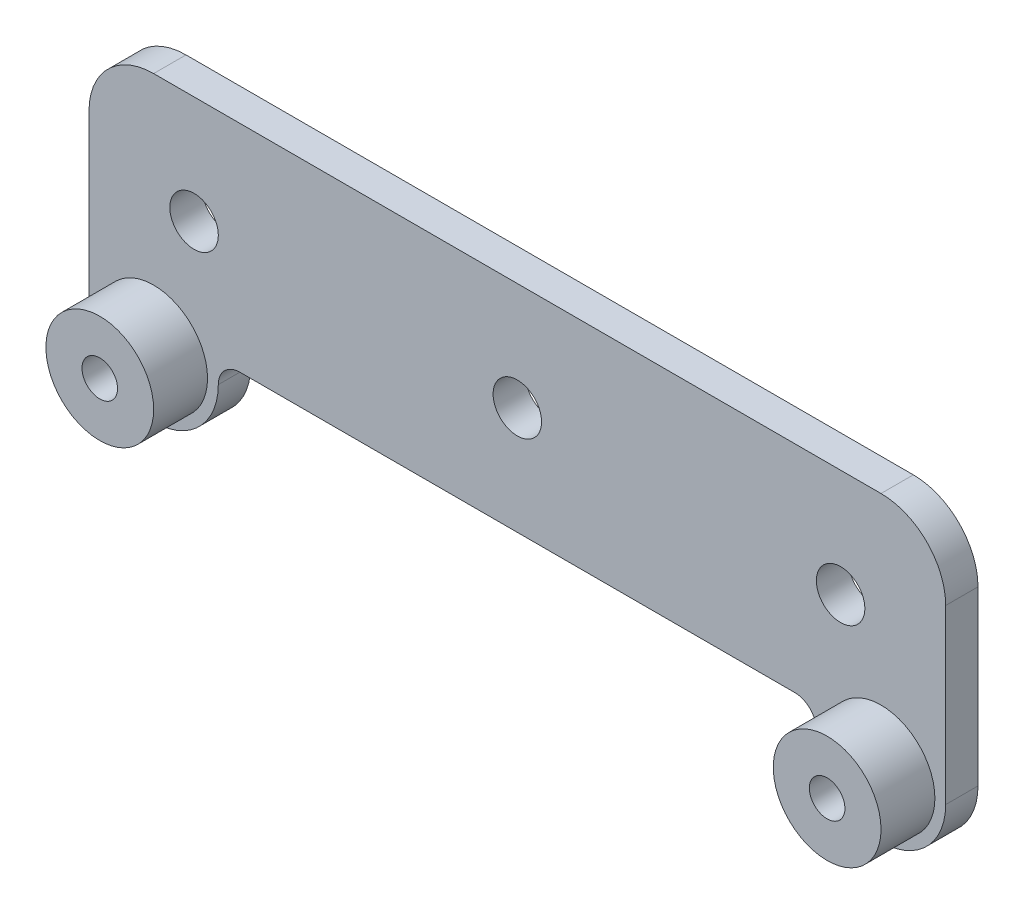
from build123d import *

# Parameters (mm, degrees)
EXTRUDE_1_DEPTH    = 3
SKETCH_4_R         = 5
EXTRUDE_2_DEPTH    = 5
M4X0_7_1_D         = 3.3
HOLE_WIZARD_M4_1_D = 4.5


with BuildPart() as part:
    # 草圖1 → 填料-伸長1 (new body)
    with BuildSketch(Plane.XY):
        with BuildLine():
            Line((-33.75, 10), (33.75, 10))
            ThreePointArc((33.75, 10), (37.992640687, 8.242640687), (39.75, 4))
            Line((39.75, 4), (39.75, -12))
            ThreePointArc((39.75, -12), (33.75, -18), (27.75, -12))
            ThreePointArc((27.75, -12), (27.164213562, -10.585786438), (25.75, -10))
            Line((25.75, -10), (-25.75, -10))
            ThreePointArc((-25.75, -10), (-27.164213562, -10.585786438), (-27.75, -12))
            ThreePointArc((-27.75, -12), (-33.75, -18), (-39.75, -12))
            Line((-39.75, -12), (-39.75, 4))
            ThreePointArc((-39.75, 4), (-37.992640687, 8.242640687), (-33.75, 10))
        make_face()
    extrude(amount=EXTRUDE_1_DEPTH)

    # 草圖4 → 填料-伸長2 (add)
    with BuildSketch(Plane.XY.offset(3)):
        with Locations((-33.75, -12)):
            Circle(SKETCH_4_R)
        with Locations((33.75, -12)):
            Circle(SKETCH_4_R)
    extrude(amount=EXTRUDE_2_DEPTH)

    # M4x0.7 螺紋孔1 (through all)
    with Locations(Plane.XY.offset(8)):
        with Locations((-33.75, -12), (33.75, -12)):
            Hole(M4X0_7_1_D / 2)

    # M4 餘隙孔1 (through all)
    with Locations(Plane.XY.offset(3)):
        with Locations((-30, 0), (30, 0), (0, 0)):
            Hole(HOLE_WIZARD_M4_1_D / 2)


solid = part.part
